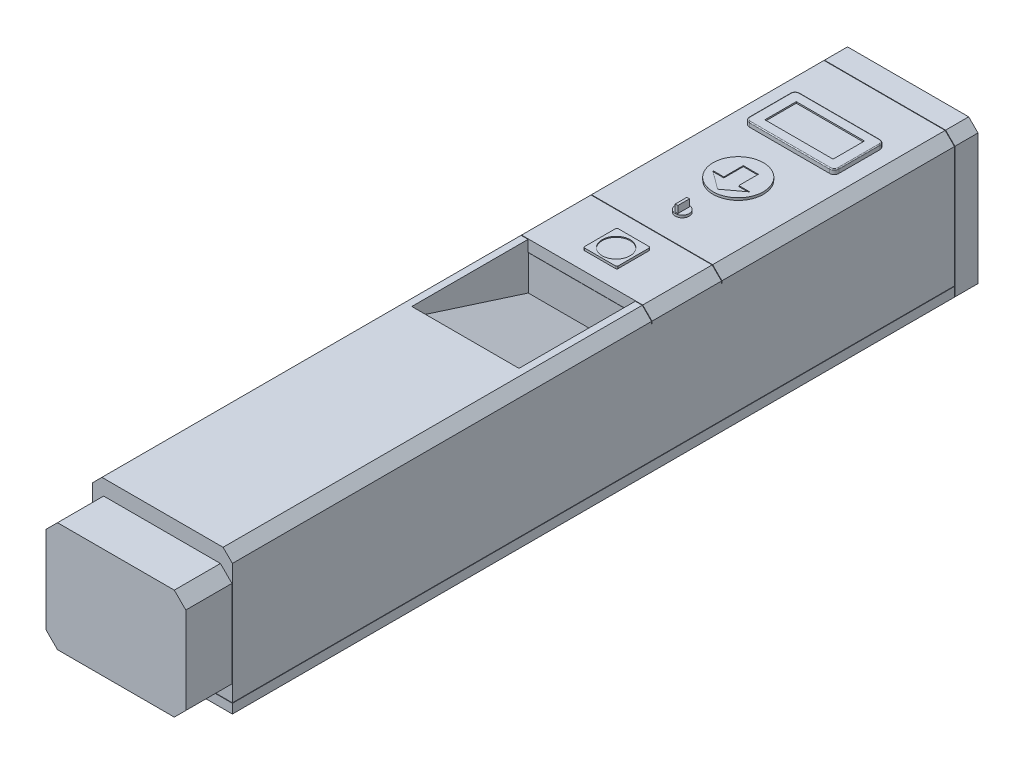
from build123d import *

# Parameters (mm, degrees)
SKETCH_1_W             = 300
SKETCH_1_H             = 300
EXTRUDE_1_DEPTH        = 1700
SKETCH_2_W             = 300
SKETCH_2_H             = 1
CUT_EXTRUDE_1_DEPTH    = 1800
CUT_EXTRUDE_2_DEPTH    = 100
CHAMFER_1_SIZE         = 20
SKETCH_5_W             = 477.672274662
SKETCH_5_H             = 1
CUT_EXTRUDE_3_DEPTH    = 331
SKETCH_6_W             = 1549.5
SKETCH_6_H             = 1
CUT_EXTRUDE_4_DEPTH    = 331
CUT_EXTRUDE_5_DEPTH    = 115
SKETCH_8_W             = 546.124938844
SKETCH_8_H             = 1
CUT_EXTRUDE_6_DEPTH    = 25
PATTERN_LINEAR_1_COUNT = 2
PATTERN_LINEAR_1_PITCH = 150
SKETCH_9_W             = 192
SKETCH_9_H             = 108
EXTRUDE_2_DEPTH        = 10
FILLET_1_R             = 10
FILLET_2_R             = 2
SKETCH_10_W            = 146.342820748
SKETCH_10_H            = 67.37146225
CUT_EXTRUDE_7_DEPTH    = 3
SKETCH_11_W            = 72
SKETCH_11_H            = 72
EXTRUDE_3_DEPTH        = 5
FILLET_3_R             = 3
SKETCH_12_R            = 30
CUT_EXTRUDE_8_DEPTH    = 2
SKETCH_13_R            = 54
SKETCH_13_R_2          = 15
EXTRUDE_4_DEPTH        = 5
SKETCH_14_W            = 5.558591624
SKETCH_14_H            = 25.092991566
EXTRUDE_5_DEPTH        = 15
CUT_EXTRUDE_9_DEPTH    = 2


with BuildPart() as part:
    # 草图1 → 凸台-拉伸1 (new body)
    with BuildSketch(Plane.XY):
        Rectangle(SKETCH_1_W, SKETCH_1_H)
    extrude(amount=EXTRUDE_1_DEPTH)

    # 草图2 → 切除-拉伸1 (cut)
    with BuildSketch(Plane(origin=(0, 150, 0), x_dir=(1, 0, 0), z_dir=(0, 1, 0))):
        with Locations((0, -1600.5)):
            Rectangle(SKETCH_2_W, SKETCH_2_H)
    extrude(amount=-CUT_EXTRUDE_1_DEPTH, mode=Mode.SUBTRACT)

    # 草图3 → 切除-拉伸2 (cut)
    with BuildSketch(Plane.XY.offset(1700)):
        Polygon((150, -93.355636265), (236.579596326, -93.355636265), (236.579596326, -247.079729733), (-236.579596326, -247.079729733), (-236.579596326, -93.355636265), (-150, -93.355636265), (-125.312415712, -118.043220553), (125.312415712, -118.043220553), align=None)
        Polygon((-150, 93.355636265), (-236.579596326, 93.355636265), (-236.579596326, 247.079729733), (236.579596326, 247.079729733), (236.579596326, 93.355636265), (150, 93.355636265), (125.312415712, 118.043220553), (-125.312415712, 118.043220553), align=None)
    extrude(amount=-CUT_EXTRUDE_2_DEPTH, mode=Mode.SUBTRACT)

    # 倒角1
    chamfer_1_edges = [part.edges().sort_by_distance(p)[0] for p in [
        (150, 150, 800),
        (-150, 150, 800),
    ]]
    chamfer(chamfer_1_edges, length=CHAMFER_1_SIZE)

    # 草图5 → 切除-拉伸3 (cut)
    with BuildSketch(Plane(origin=(0, 150, 0), x_dir=(1, 0, 0), z_dir=(0, 1, 0))):
        with Locations((0, -50)):
            Rectangle(SKETCH_5_W, SKETCH_5_H)
    extrude(amount=-CUT_EXTRUDE_3_DEPTH, mode=Mode.SUBTRACT)

    # 草图6 → 切除-拉伸4 (cut)
    with BuildSketch(Plane(origin=(150, 0, 0), x_dir=(0, 0, -1), z_dir=(1, 0, 0))):
        with Locations((-825.25, -129.5)):
            Rectangle(SKETCH_6_W, SKETCH_6_H)
    extrude(amount=-CUT_EXTRUDE_4_DEPTH, mode=Mode.SUBTRACT)

    # 草图7 → 切除-拉伸5 (cut, symmetric)
    with BuildSketch(Plane(origin=(0, 0, 0), x_dir=(0, 0, -1), z_dir=(1, 0, 0))):
        Polygon((-700, 150), (-950, 150), (-950, 130), (-700, 50), align=None)
    extrude(amount=CUT_EXTRUDE_5_DEPTH, both=True, mode=Mode.SUBTRACT)

    # 草图8 → 切除-拉伸6 (cut)
    with BuildSketch(Plane(origin=(0, 150, 0), x_dir=(1, 0, 0), z_dir=(0, 1, 0))):
        with Locations((0, -550)):
            Rectangle(SKETCH_8_W, SKETCH_8_H)
    cut_extrude_6 = extrude(amount=-CUT_EXTRUDE_6_DEPTH, mode=Mode.SUBTRACT)

    # 阵列(线性)1: 切除-拉伸6 ×2
    with Locations(*[(0, 0, i * PATTERN_LINEAR_1_PITCH) for i in range(1, PATTERN_LINEAR_1_COUNT)]):
        add(cut_extrude_6, mode=Mode.SUBTRACT)

    # 草图9 → 凸台-拉伸2 (add)
    with BuildSketch(Plane(origin=(0, 150, 0), x_dir=(1, 0, 0), z_dir=(0, 1, 0))):
        with Locations((0, -200.5)):
            Rectangle(SKETCH_9_W, SKETCH_9_H)
    extrude(amount=EXTRUDE_2_DEPTH)

    # 圆角1
    fillet_1_edges = [part.edges().sort_by_distance(p)[0] for p in [
        (96, 155, 254.5),
        (96, 155, 146.5),
        (-96, 155, 146.5),
        (-96, 155, 254.5),
    ]]
    fillet(fillet_1_edges, radius=FILLET_1_R)

    # 圆角2
    fillet_2_edges = [part.edges().sort_by_distance(p)[0] for p in [
        (-96, 160, 200.5),
        (0, 160, 146.5),
        (96, 160, 200.5),
        (0, 160, 254.5),
        (93.071067812, 160, 149.428932188),
        (93.071067812, 160, 251.571067812),
        (-93.071067812, 160, 251.571067812),
        (-93.071067812, 160, 149.428932188),
    ]]
    fillet(fillet_2_edges, radius=FILLET_2_R)

    # 草图10 → 切除-拉伸7 (cut)
    with BuildSketch(Plane(origin=(0, 160, 0), x_dir=(1, 0, 0), z_dir=(0, 1, 0))):
        with Locations((0, -200.5)):
            Rectangle(SKETCH_10_W, SKETCH_10_H)
    extrude(amount=-CUT_EXTRUDE_7_DEPTH, mode=Mode.SUBTRACT)

    # 草图11 → 凸台-拉伸3 (add)
    with BuildSketch(Plane(origin=(0, 150, 0), x_dir=(1, 0, 0), z_dir=(0, 1, 0))):
        with Locations((0, -625)):
            Rectangle(SKETCH_11_W, SKETCH_11_H)
    extrude(amount=EXTRUDE_3_DEPTH)

    # 圆角3
    fillet_3_edges = [part.edges().sort_by_distance(p)[0] for p in [
        (36, 152.5, 661),
        (36, 152.5, 589),
        (-36, 152.5, 589),
        (-36, 152.5, 661),
    ]]
    fillet(fillet_3_edges, radius=FILLET_3_R)

    # 草图12 → 切除-拉伸8 (cut)
    with BuildSketch(Plane(origin=(0, 155, 0), x_dir=(1, 0, 0), z_dir=(0, 1, 0))):
        with Locations((0, -626.513071867)):
            Circle(SKETCH_12_R)
    extrude(amount=-CUT_EXTRUDE_8_DEPTH, mode=Mode.SUBTRACT)

    # 草图13 → 凸台-拉伸4 (add)
    with BuildSketch(Plane(origin=(0, 150, 0), x_dir=(1, 0, 0), z_dir=(0, 1, 0))):
        with Locations((0, -364.5)):
            Circle(SKETCH_13_R)
        with Locations((0, -484.5)):
            Circle(SKETCH_13_R_2)
    extrude(amount=EXTRUDE_4_DEPTH)

    # 草图14 → 凸台-拉伸5 (add)
    with BuildSketch(Plane(origin=(0, 155, 0), x_dir=(1, 0, 0), z_dir=(0, 1, 0))):
        with Locations((0, -484.5)):
            Rectangle(SKETCH_14_W, SKETCH_14_H)
    extrude(amount=EXTRUDE_5_DEPTH)

    # 草图15 → 切除-拉伸9 (cut)
    with BuildSketch(Plane(origin=(0, 155, 0), x_dir=(1, 0, 0), z_dir=(0, 1, 0))):
        Polygon((16.100670748, -337.5), (-16.100670748, -337.5), (-16.100670748, -379.375728248), (-39.763314653, -379.375728248), (0, -408.943051302), (39.763314653, -379.375728248), (16.100670748, -379.375728248), align=None)
    extrude(amount=-CUT_EXTRUDE_9_DEPTH, mode=Mode.SUBTRACT)


solid = part.part
